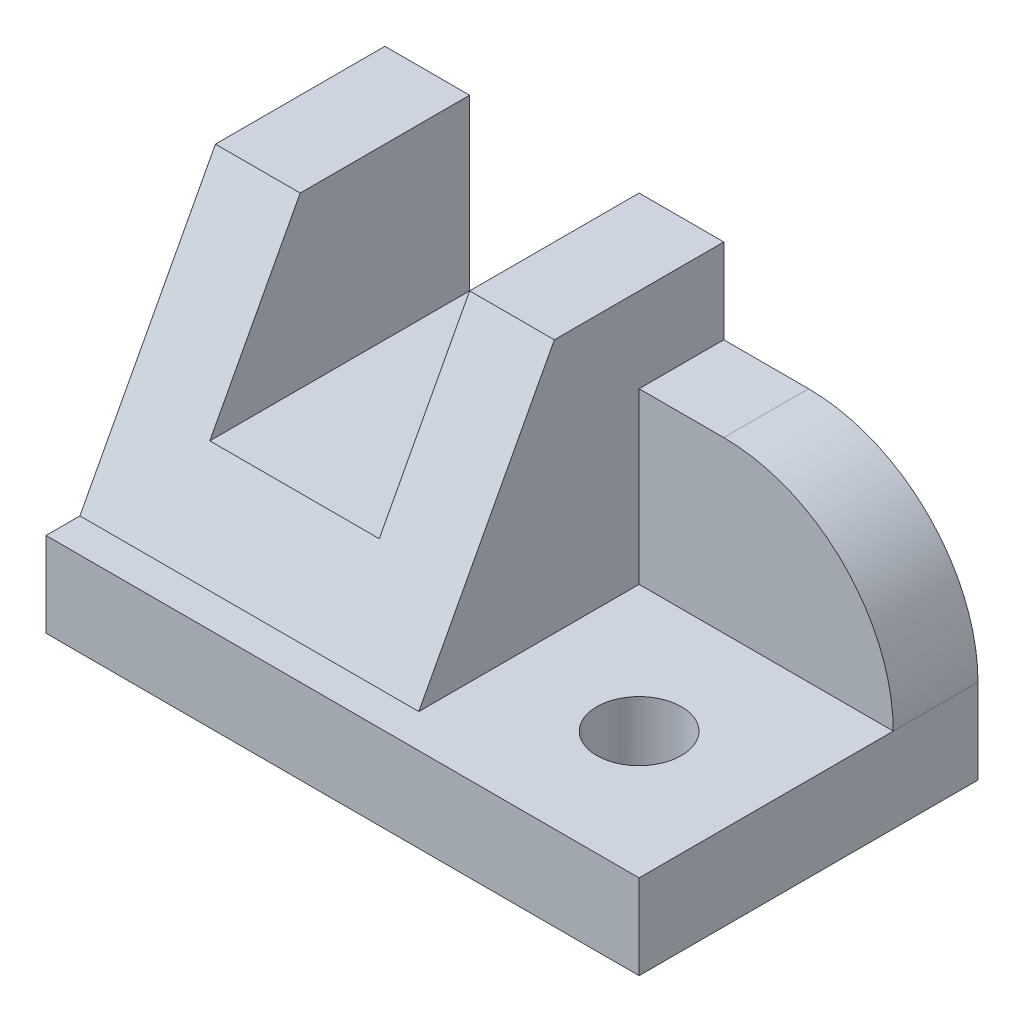
from build123d import *

# Parameters (mm, degrees)
BOSS_EXTRUDE1_DEPTH            = 40
SKETCH2_W                      = 40
SKETCH2_H                      = 30
BOSS_EXTRUDE2_DEPTH            = 20
BOSS_EXTRUDE3_DEPTH            = 30
CUT_EXTRUDE1_DEPTH             = 30
SKETCH5_W                      = 70
SKETCH5_H                      = 40
BOSS_EXTRUDE4_DEPTH            = 10
SKETCH6_W                      = 20
SKETCH6_H                      = 20
CUT_EXTRUDE2_DEPTH             = 41
F_10_0_10_DIAMETER_HOLE1_D     = 10
F_10_0_10_DIAMETER_HOLE1_DEPTH = 40
FILLET1_R                      = 20


with BuildPart() as part:
    # Sketch1 → Boss-Extrude1 (new body)
    with BuildSketch(Plane(origin=(0, 0, 0), x_dir=(0, -1, 0), z_dir=(-1, 0, 0))):
        Polygon((-10, -4), (-40, -20), (-10, -20), align=None)
    extrude(amount=-BOSS_EXTRUDE1_DEPTH)

    # Sketch2 → Boss-Extrude2 (add)
    with BuildSketch(Plane(origin=(0, 0, -20), x_dir=(-1, 0, 0), z_dir=(0, 0, -1))):
        with Locations((-20, 25)):
            Rectangle(SKETCH2_W, SKETCH2_H)
    extrude(amount=BOSS_EXTRUDE2_DEPTH)

    # Sketch3 → Boss-Extrude3 (add)
    with BuildSketch(Plane(origin=(40, 0, 0), x_dir=(0, 0, -1), z_dir=(1, 0, 0))):
        Polygon((40, 10), (0, 10), (20, 40), (40, 40), align=None)
    extrude(amount=BOSS_EXTRUDE3_DEPTH)

    # Sketch4 → Cut-Extrude1 (cut)
    with BuildSketch(Plane(origin=(70, 0, 0), x_dir=(0, 0, -1), z_dir=(1, 0, 0))):
        Polygon((20, 40), (0, 10), (30, 10), (30, 30), (40, 30), (40, 40), align=None)
    extrude(amount=-CUT_EXTRUDE1_DEPTH, mode=Mode.SUBTRACT)

    # Sketch5 → Boss-Extrude4 (add)
    with BuildSketch(Plane.XZ.offset(-10)):
        with Locations((35, -20)):
            Rectangle(SKETCH5_W, SKETCH5_H)
    extrude(amount=BOSS_EXTRUDE4_DEPTH)

    # Sketch6 → Cut-Extrude2 (cut, through all)
    with BuildSketch(Plane(origin=(0, 0, -40), x_dir=(-1, 0, 0), z_dir=(0, 0, -1))):
        with Locations((-20, 30)):
            Rectangle(SKETCH6_W, SKETCH6_H)
    extrude(amount=-CUT_EXTRUDE2_DEPTH, mode=Mode.SUBTRACT)

    # Ø10.0 (10) Diameter Hole1
    with Locations(Plane(origin=(0, 0, 0), x_dir=(-1, 0, 0), z_dir=(0, -1, 0))):
        with Locations((-55, 15)):
            Hole(F_10_0_10_DIAMETER_HOLE1_D / 2, depth=F_10_0_10_DIAMETER_HOLE1_DEPTH)

    # Fillet1
    fillet1_edges = [part.edges().sort_by_distance(p)[0] for p in [
        (70, 30, -35),
    ]]
    fillet(fillet1_edges, radius=FILLET1_R)


solid = part.part
